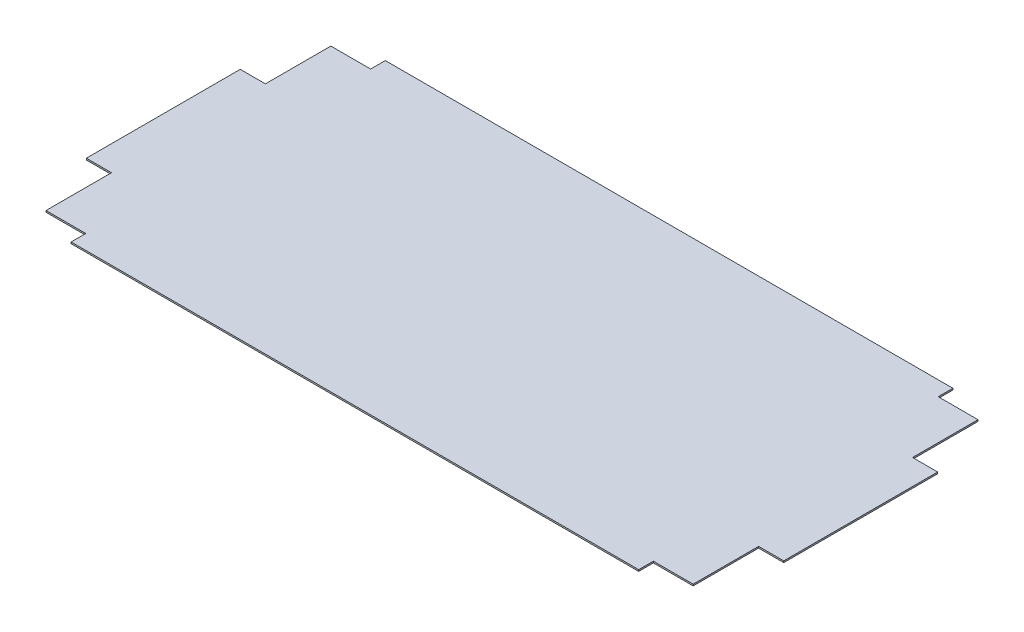
from build123d import *

# Parameters (mm, degrees)
CROQUIS1_W              = 666
CROQUIS1_H              = 300
SALIENTE_EXTRUIR1_DEPTH = 1.5
CROQUIS2_W              = 24
CROQUIS2_H              = 46.5
CORTAR_EXTRUIR1_DEPTH   = 2.5
CROQUIS3_W              = 38
CROQUIS3_H              = 14
CORTAR_EXTRUIR2_DEPTH   = 2.5
CROQUIS5_W              = 24
CROQUIS5_H              = 30
CORTAR_EXTRUIR3_DEPTH   = 2.5


with BuildPart() as part:
    # Croquis1 → Saliente-Extruir1 (new body)
    with BuildSketch(Plane(origin=(0, 0, 0), x_dir=(1, 0, 0), z_dir=(0, 1, 0))):
        Rectangle(CROQUIS1_W, CROQUIS1_H)
    extrude(amount=SALIENTE_EXTRUIR1_DEPTH)

    # Croquis2 → Cortar-Extruir1 (cut, through all)
    with BuildSketch(Plane(origin=(0, 1.5, 0), x_dir=(1, 0, 0), z_dir=(0, 1, 0))):
        with Locations((321, 126.75)):
            Rectangle(CROQUIS2_W, CROQUIS2_H)
        with Locations((-321, 126.75)):
            Rectangle(CROQUIS2_W, CROQUIS2_H)
        with Locations((-321, -126.75)):
            Rectangle(CROQUIS2_W, CROQUIS2_H)
        with Locations((321, -126.75)):
            Rectangle(CROQUIS2_W, CROQUIS2_H)
    extrude(amount=-CORTAR_EXTRUIR1_DEPTH, mode=Mode.SUBTRACT)

    # Croquis3 → Cortar-Extruir2 (cut, through all)
    with BuildSketch(Plane(origin=(0, 1.5, 0), x_dir=(1, 0, 0), z_dir=(0, 1, 0))):
        with Locations((-290, 143)):
            Rectangle(CROQUIS3_W, CROQUIS3_H)
        with Locations((290, 143)):
            Rectangle(CROQUIS3_W, CROQUIS3_H)
        with Locations((290, -143)):
            Rectangle(CROQUIS3_W, CROQUIS3_H)
        with Locations((-290, -143)):
            Rectangle(CROQUIS3_W, CROQUIS3_H)
    extrude(amount=-CORTAR_EXTRUIR2_DEPTH, mode=Mode.SUBTRACT)

    # Croquis5 → Cortar-Extruir3 (cut, through all)
    with BuildSketch(Plane(origin=(0, 1.5, 0), x_dir=(1, 0, 0), z_dir=(0, 1, 0))):
        with Locations((-321, 88.5)):
            Rectangle(CROQUIS5_W, CROQUIS5_H)
        with Locations((321, 88.5)):
            Rectangle(CROQUIS5_W, CROQUIS5_H)
        with Locations((321, -88.5)):
            Rectangle(CROQUIS5_W, CROQUIS5_H)
        with Locations((-321, -88.5)):
            Rectangle(CROQUIS5_W, CROQUIS5_H)
    extrude(amount=-CORTAR_EXTRUIR3_DEPTH, mode=Mode.SUBTRACT)


solid = part.part
